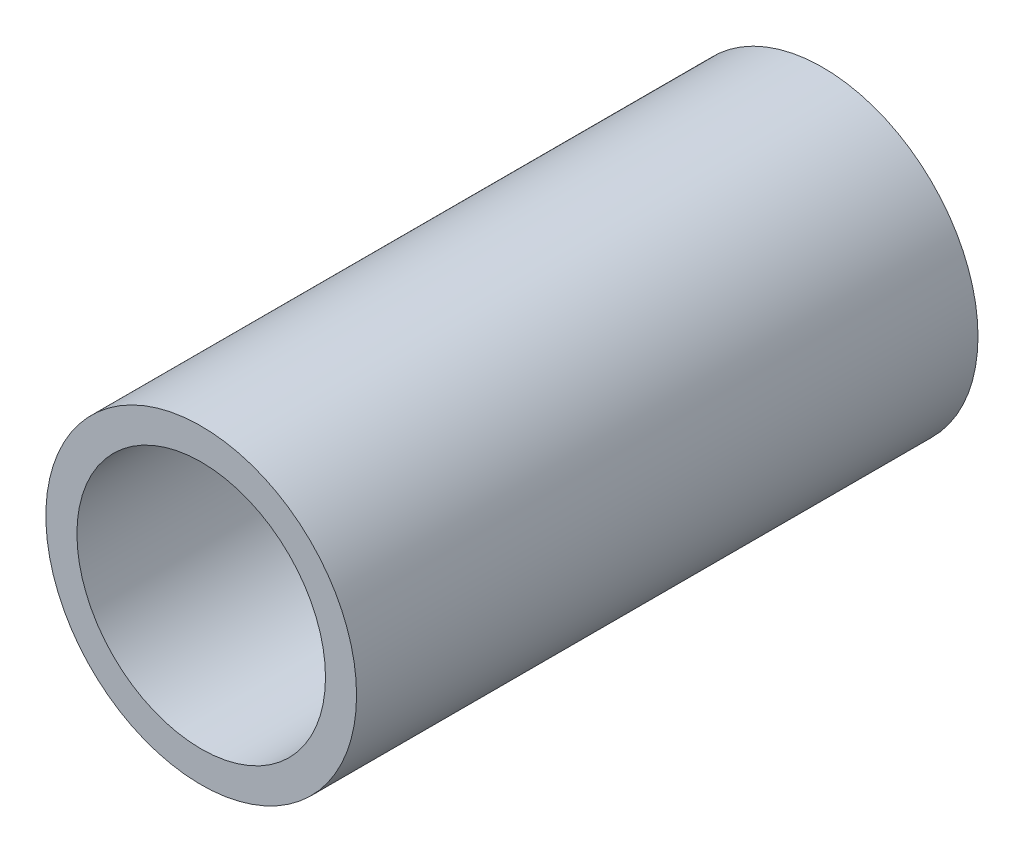
from build123d import *

# Parameters (mm, degrees)
SKETCH1_R      = 50
SKETCH1_R_2    = 40
EXTRUDE1_DEPTH = 200


with BuildPart() as part:
    # Sketch1 → Extrude1 (new body)
    with BuildSketch(Plane.XY):
        Circle(SKETCH1_R)
        Circle(SKETCH1_R_2, mode=Mode.SUBTRACT)
    extrude(amount=EXTRUDE1_DEPTH)


solid = part.part
